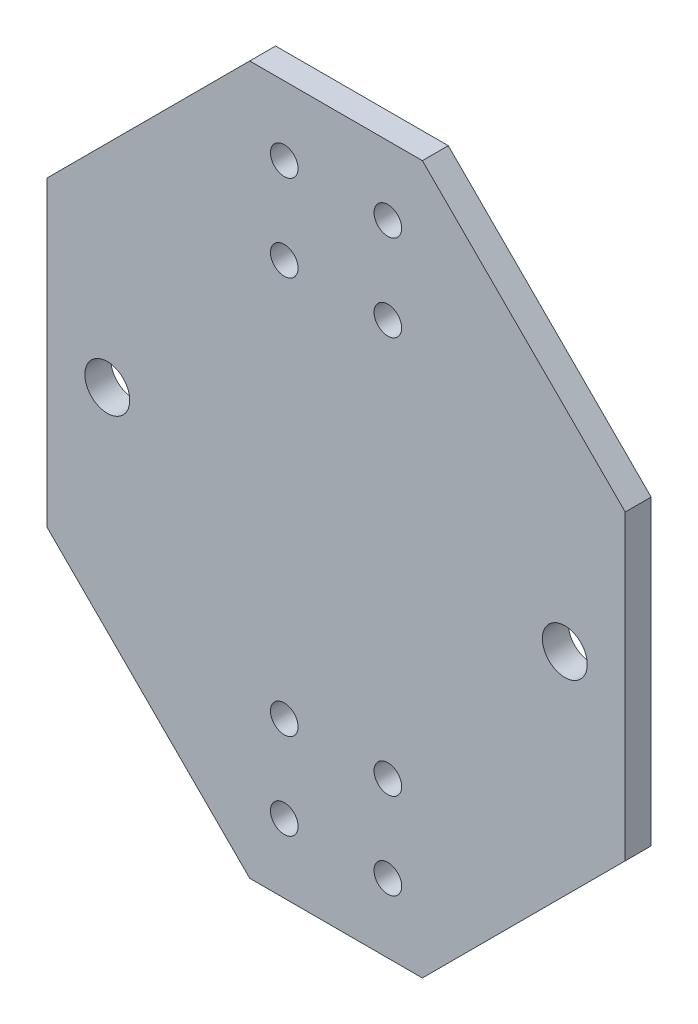
from build123d import *

# Parameters (mm, degrees)
SKETCH1_R           = 2.6
SKETCH1_R_2         = 1.6
BOSS_EXTRUDE1_DEPTH = 3


with BuildPart() as part:
    # Sketch1 → Boss-Extrude1 (new body)
    with BuildSketch(Plane.XY):
        Polygon((-70.000568612, -293.594950635), (-50.000568612, -293.594950635), (-26.500568612, -317.094950635), (-26.500568612, -352.094950635), (-50.000568612, -375.594950635), (-70.000568612, -375.594950635), (-93.500568612, -352.094950635), (-93.500568612, -317.094950635), align=None)
        with Locations((-86.500568612, -334.594950635)):
            Circle(SKETCH1_R, mode=Mode.SUBTRACT)
        with Locations((-33.500568612, -334.594950635)):
            Circle(SKETCH1_R, mode=Mode.SUBTRACT)
        with Locations((-66.000568612, -301.594950635)):
            Circle(SKETCH1_R_2, mode=Mode.SUBTRACT)
        with Locations((-54.000568612, -301.594950635)):
            Circle(SKETCH1_R_2, mode=Mode.SUBTRACT)
        with Locations((-66.000568612, -367.594950635)):
            Circle(SKETCH1_R_2, mode=Mode.SUBTRACT)
        with Locations((-54.000568612, -367.594950635)):
            Circle(SKETCH1_R_2, mode=Mode.SUBTRACT)
        with Locations((-66.000568612, -311.594950635)):
            Circle(SKETCH1_R_2, mode=Mode.SUBTRACT)
        with Locations((-54.000568612, -311.594950635)):
            Circle(SKETCH1_R_2, mode=Mode.SUBTRACT)
        with Locations((-66.000568612, -357.594950635)):
            Circle(SKETCH1_R_2, mode=Mode.SUBTRACT)
        with Locations((-54.000568612, -357.594950635)):
            Circle(SKETCH1_R_2, mode=Mode.SUBTRACT)
    extrude(amount=BOSS_EXTRUDE1_DEPTH)


solid = part.part
